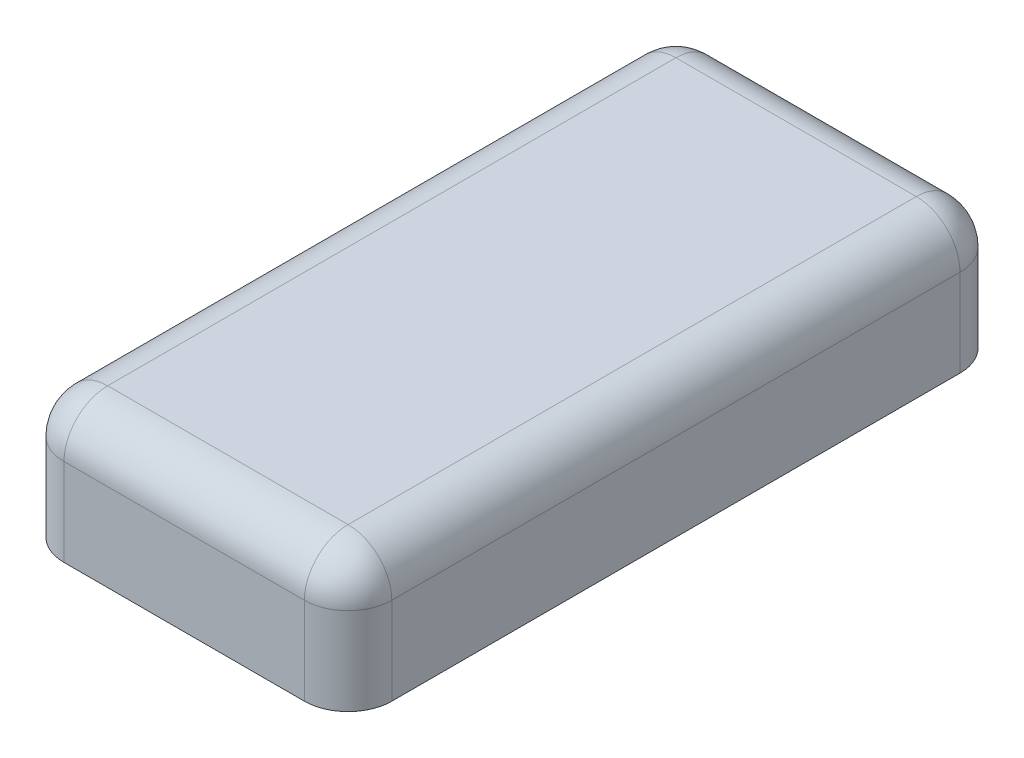
from build123d import *

# Parameters (mm, degrees)
BASES_W    = 1.5
BASES_H    = 3
BASE_DEPTH = 0.6
SIDEF_R    = 0.2
TOPF_R     = 0.2


with BuildPart() as part:
    # BaseS → Base (new body)
    with BuildSketch(Plane(origin=(0, 0, 0), x_dir=(1, 0, 0), z_dir=(0, 1, 0))):
        Rectangle(BASES_W, BASES_H)
    extrude(amount=BASE_DEPTH)

    # SideF
    sidef_edges = [part.edges().sort_by_distance(p)[0] for p in [
        (0.75, 0.3, 1.5),
        (-0.75, 0.3, 1.5),
        (-0.75, 0.3, -1.5),
        (0.75, 0.3, -1.5),
    ]]
    fillet(sidef_edges, radius=SIDEF_R)

    # TopF
    topf_edges = [part.edges().sort_by_distance(p)[0] for p in [
        (0.75, 0.6, 0),
        (0, 0.6, 1.5),
        (0, 0.6, -1.5),
        (-0.75, 0.6, 0),
        (-0.691421356, 0.6, -1.441421356),
        (-0.691421356, 0.6, 1.441421356),
        (0.691421356, 0.6, -1.441421356),
        (0.691421356, 0.6, 1.441421356),
    ]]
    fillet(topf_edges, radius=TOPF_R)


solid = part.part
